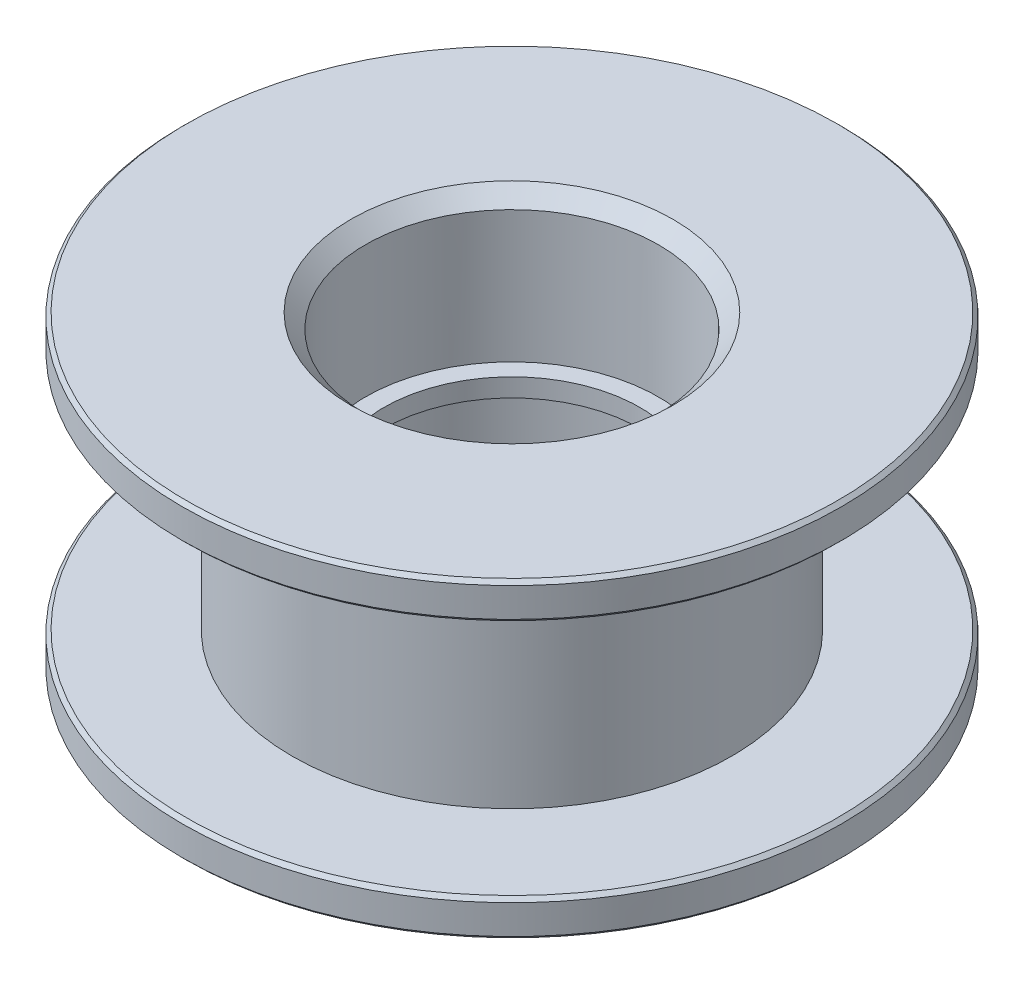
from build123d import *

# Parameters (mm, degrees)
INNERC_SIZE = 0.4
OUTERC_SIZE = 0.1


with BuildPart() as part:
    # BodyS → Body (revolve)
    with BuildSketch(Plane.XY):
        Polygon((6, -3.25), (6, 3.25), (9, 3.25), (9, 4.25), (4, 4.25), (4, 0.25), (3.5, 0.25), (3.5, -0.25), (4, -0.25), (4, -4.25), (9, -4.25), (9, -3.25), align=None)
    revolve(axis=Axis((0, 4.25, 0), (0, -1, 0)))

    # InnerC
    innerc_edges = [part.edges().sort_by_distance(p)[0] for p in [
        (-4, -4.25, 0),
        (-4, 4.25, 0),
    ]]
    chamfer(innerc_edges, length=INNERC_SIZE)

    # OuterC
    outerc_edges = [part.edges().sort_by_distance(p)[0] for p in [
        (-9, 4.25, 0),
        (-9, 3.25, 0),
        (-9, -3.25, 0),
        (-9, -4.25, 0),
    ]]
    chamfer(outerc_edges, length=OUTERC_SIZE)


solid = part.part
